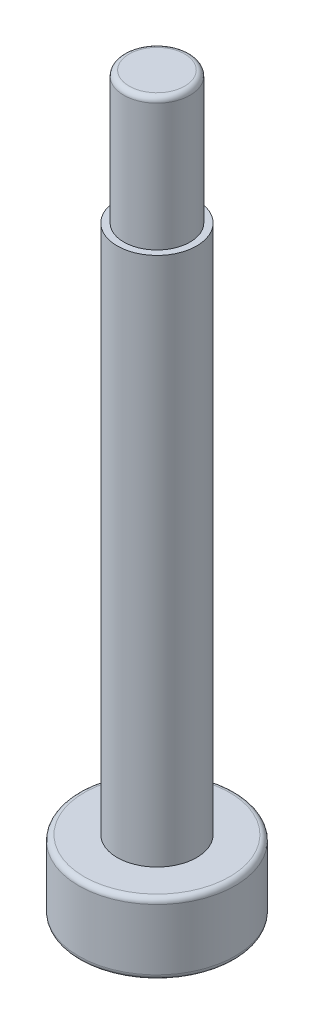
from build123d import *

# Parameters (mm, degrees)
SKETCH_1_R          = 2.95
EXTRUDE_1_DEPTH     = 2.7
SKETCH_2_R          = 1.5
EXTRUDE_2_DEPTH     = 20
SKETCH_3_R          = 1.25
EXTRUDE_3_DEPTH     = 5
CUT_EXTRUDE_1_DEPTH = 2
FILLET_1_R          = 0.2


with BuildPart() as part:
    # 草图1 → 凸台-拉伸1 (new body)
    with BuildSketch(Plane(origin=(0, 0, 0), x_dir=(1, 0, 0), z_dir=(0, 1, 0))):
        Circle(SKETCH_1_R)
    extrude(amount=EXTRUDE_1_DEPTH)

    # 草图2 → 凸台-拉伸2 (add)
    with BuildSketch(Plane(origin=(0, 2.7, 0), x_dir=(1, 0, 0), z_dir=(0, 1, 0))):
        Circle(SKETCH_2_R)
    extrude(amount=EXTRUDE_2_DEPTH)

    # 草图3 → 凸台-拉伸3 (add)
    with BuildSketch(Plane(origin=(0, 22.7, 0), x_dir=(1, 0, 0), z_dir=(0, 1, 0))):
        Circle(SKETCH_3_R)
    extrude(amount=EXTRUDE_3_DEPTH)

    # 草图4 → 切除-拉伸1 (cut)
    with BuildSketch(Plane.XZ):
        Polygon((2.247285488, -0.53201623), (1.584382314, 1.680198207), (-0.662903174, 2.212214437), (-2.247285488, 0.53201623), (-1.584382314, -1.680198207), (0.662903174, -2.212214437), align=None)
    extrude(amount=-CUT_EXTRUDE_1_DEPTH, mode=Mode.SUBTRACT)

    # 圆角1
    fillet_1_edges = [part.edges().sort_by_distance(p)[0] for p in [
        (-1.25, 27.7, 0),
        (-2.95, 0, 0),
        (-2.95, 2.7, 0),
    ]]
    fillet(fillet_1_edges, radius=FILLET_1_R)


solid = part.part
